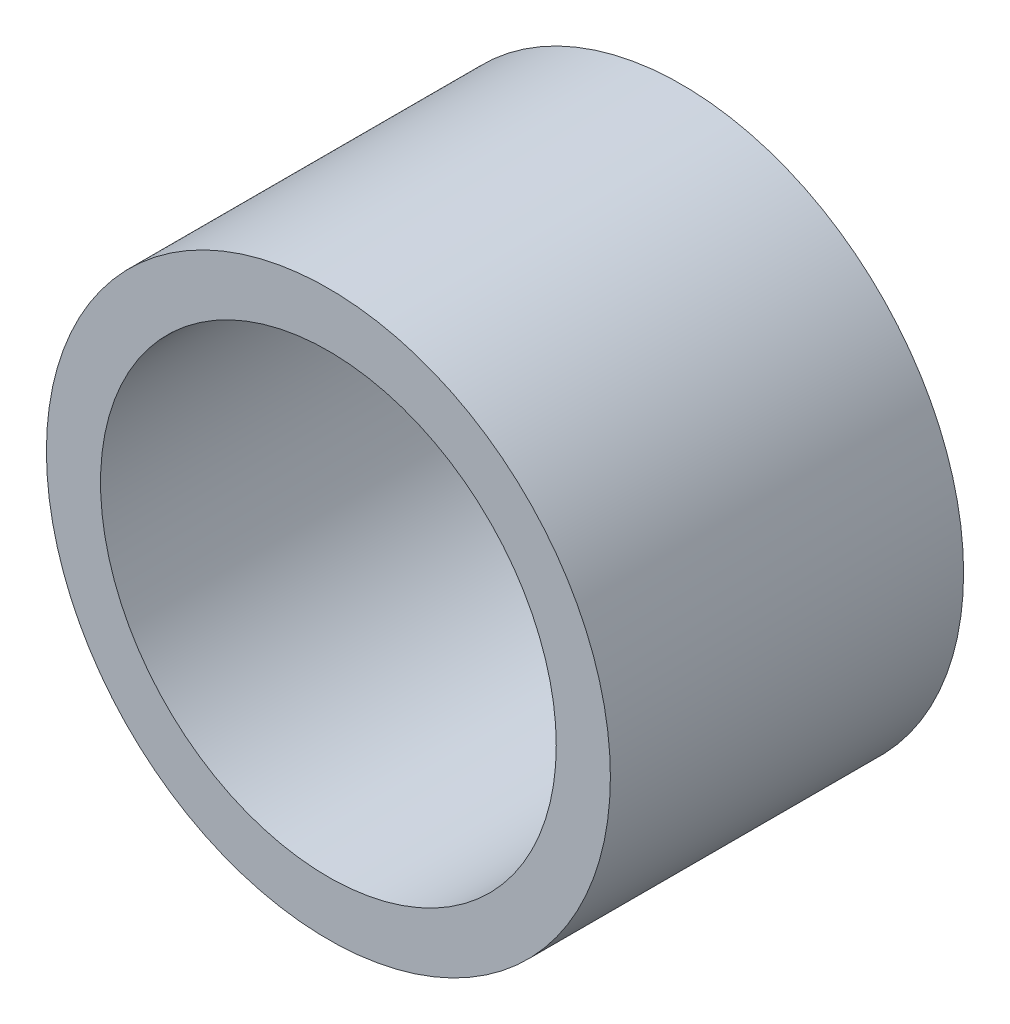
from build123d import *

# Parameters (mm, degrees)
SKETCH1_R      = 6.2865
SKETCH1_R_2    = 5.08
EXTRUDE1_DEPTH = 7.874


with BuildPart() as part:
    # Sketch1 → Extrude1 (new body)
    with BuildSketch(Plane.XY):
        Circle(SKETCH1_R)
        Circle(SKETCH1_R_2, mode=Mode.SUBTRACT)
    extrude(amount=EXTRUDE1_DEPTH)


solid = part.part
